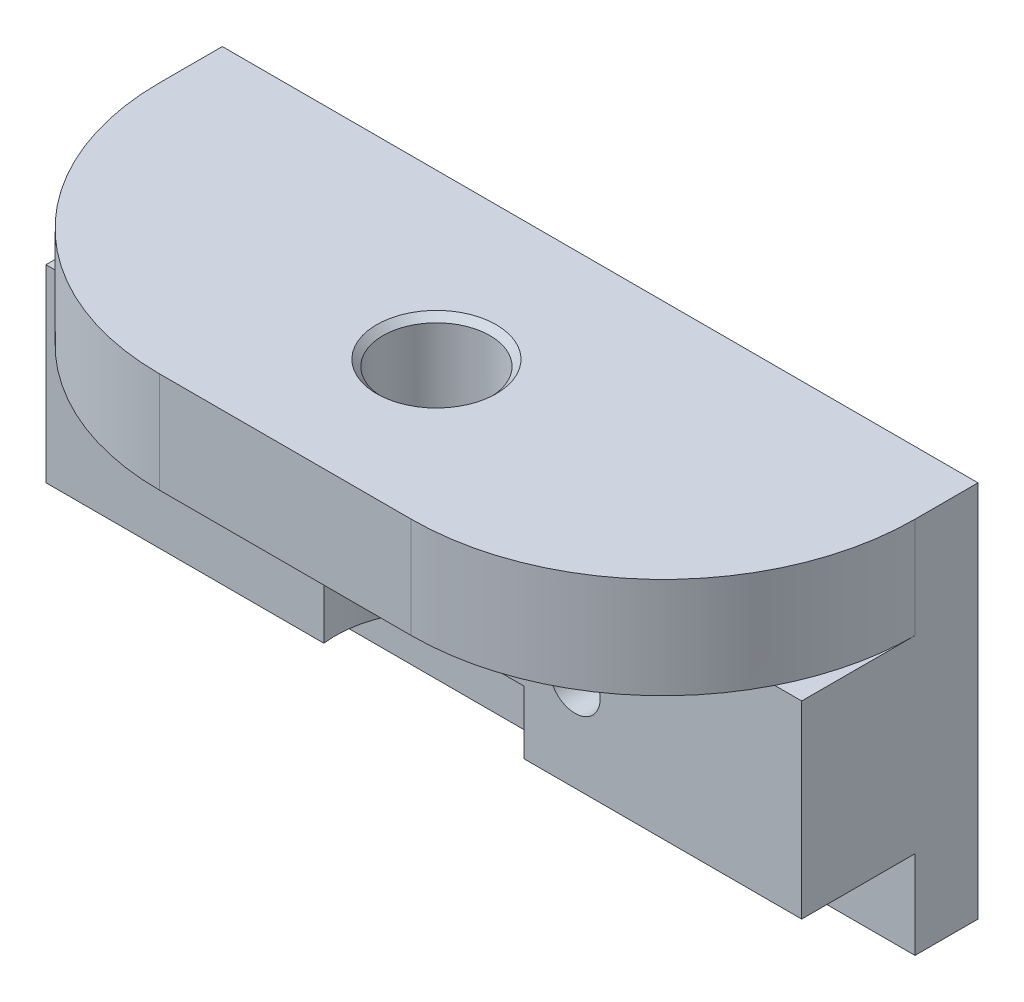
from build123d import *

# Parameters (mm, degrees)
SCHIZZO1_W                   = 60
SCHIZZO1_H                   = 30
ESTRUSIONE_ESTRUSIONE1_DEPTH = 5
SCHIZZO2_W                   = 60
SCHIZZO2_H                   = 8
ESTRUSIONE_ESTRUSIONE2_DEPTH = 20
SCHIZZO3_R                   = 4.25
TAGLIO_ESTRUSIONE1_DEPTH     = 8
RACCORDO1_R                  = 20
SCHIZZO4_W                   = 60
SCHIZZO4_H                   = 15
ESTRUSIONE_ESTRUSIONE3_DEPTH = 10
SCHIZZO6_R                   = 8
TAGLIO_ESTRUSIONE2_DEPTH     = 15
SCHIZZO8_W                   = 60
SCHIZZO8_H                   = 4.5
ESTRUSIONE_ESTRUSIONE4_DEPTH = 10
SCHIZZO9_R                   = 6.3
TAGLIO_ESTRUSIONE3_DEPTH     = 4.5
SCHIZZO10_R                  = 2
TAGLIO_ESTRUSIONE4_DEPTH     = 16
SCHIZZO11_W                  = 60
SCHIZZO11_H                  = 15
TAGLIO_ESTRUSIONE5_DEPTH     = 1
SMUSSO1_SIZE                 = 0.5


with BuildPart() as part:
    # Schizzo1 → Estrusione-Estrusione1 (new body)
    with BuildSketch(Plane.XY):
        Rectangle(SCHIZZO1_W, SCHIZZO1_H)
    extrude(amount=ESTRUSIONE_ESTRUSIONE1_DEPTH)

    # Schizzo2 → Estrusione-Estrusione2 (add)
    with BuildSketch(Plane.XY.offset(5)):
        with Locations((0, 11)):
            Rectangle(SCHIZZO2_W, SCHIZZO2_H)
    extrude(amount=ESTRUSIONE_ESTRUSIONE2_DEPTH)

    # Schizzo3 → Taglio-Estrusione1 (cut)
    with BuildSketch(Plane(origin=(0, 15, 0), x_dir=(1, 0, 0), z_dir=(0, 1, 0))):
        with Locations((0, -13)):
            Circle(SCHIZZO3_R)
    extrude(amount=-TAGLIO_ESTRUSIONE1_DEPTH, mode=Mode.SUBTRACT)

    # Raccordo1
    raccordo1_edges = [part.edges().sort_by_distance(p)[0] for p in [
        (30, 11, 25),
        (-30, 11, 25),
    ]]
    fillet(raccordo1_edges, radius=RACCORDO1_R)

    # Schizzo4 → Estrusione-Estrusione3 (add)
    with BuildSketch(Plane.XY.offset(5)):
        with Locations((0, -0.5)):
            Rectangle(SCHIZZO4_W, SCHIZZO4_H)
    extrude(amount=ESTRUSIONE_ESTRUSIONE3_DEPTH)

    # Schizzo6 → Taglio-Estrusione2 (cut)
    with BuildSketch(Plane.XZ.offset(8)):
        with Locations((0, 13)):
            Circle(SCHIZZO6_R)
    extrude(amount=-TAGLIO_ESTRUSIONE2_DEPTH, mode=Mode.SUBTRACT)

    # Schizzo8 → Estrusione-Estrusione4 (add)
    with BuildSketch(Plane.XY.offset(15)):
        with Locations((0, -0.75)):
            Rectangle(SCHIZZO8_W, SCHIZZO8_H)
    extrude(amount=-ESTRUSIONE_ESTRUSIONE4_DEPTH)

    # Schizzo9 → Taglio-Estrusione3 (cut)
    with BuildSketch(Plane.XZ.offset(3)):
        with Locations((0, 13)):
            Circle(SCHIZZO9_R)
    extrude(amount=-TAGLIO_ESTRUSIONE3_DEPTH, mode=Mode.SUBTRACT)

    # Schizzo10 → Taglio-Estrusione4 (cut, through all)
    with BuildSketch(Plane.XY.offset(15)):
        with Locations((12, -0.85)):
            Circle(SCHIZZO10_R)
        with Locations((-12, -0.85)):
            Circle(SCHIZZO10_R)
    extrude(amount=-TAGLIO_ESTRUSIONE4_DEPTH, mode=Mode.SUBTRACT)

    # Schizzo11 → Taglio-Estrusione5 (cut)
    with BuildSketch(Plane.XY.offset(15)):
        with Locations((0, -0.5)):
            Rectangle(SCHIZZO11_W, SCHIZZO11_H)
    extrude(amount=-TAGLIO_ESTRUSIONE5_DEPTH, mode=Mode.SUBTRACT)

    # Smusso1
    smusso1_edges = [part.edges().sort_by_distance(p)[0] for p in [
        (-4.25, 15, 13),
    ]]
    chamfer(smusso1_edges, length=SMUSSO1_SIZE)


solid = part.part
